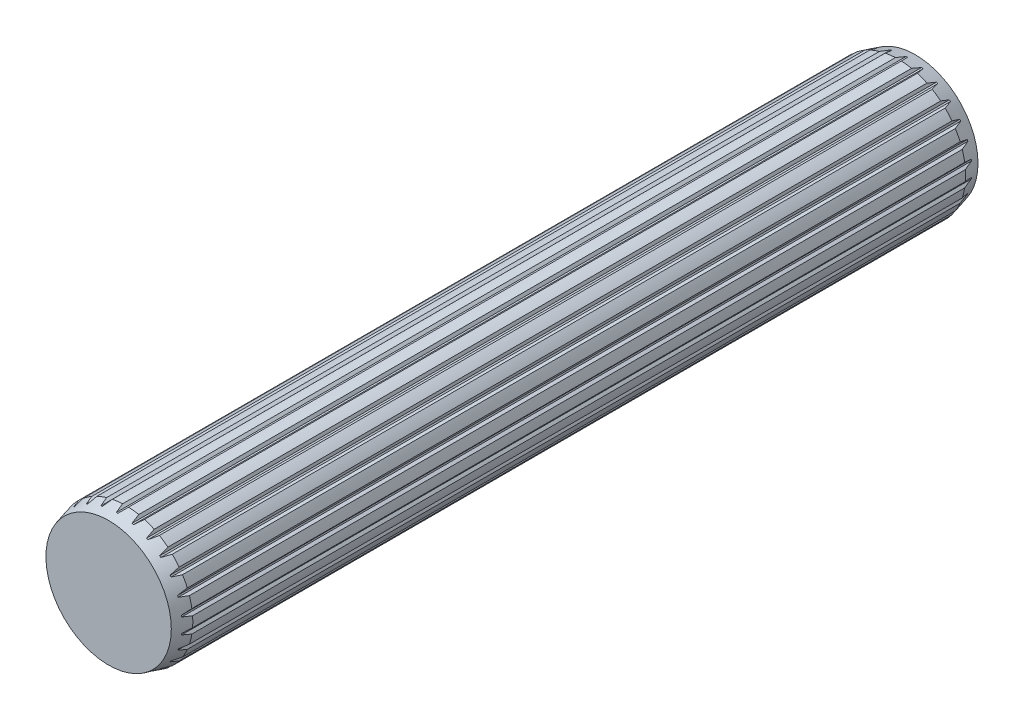
from build123d import *

# Parameters (mm, degrees)
CUT_EXTRUDE1_DEPTH = 20.05
CIRPATTERN1_COUNT  = 26


with BuildPart() as part:
    # Sketch3 → Revolve1 (revolve)
    with BuildSketch(Plane(origin=(0, 0, 0), x_dir=(0, 0, -1), z_dir=(1, 0, 0))):
        Polygon((-19.05, 2.960640646), (-19.05, 0), (19.05, 0), (19.05, 2.960640646), (18.25, 3.175), (-18.25, 3.175), align=None)
    revolve(axis=Axis((0, 0, 19.05), (0, 0, -1)))

    # Sketch5 → Cut-Extrude1 (cut, symmetric)
    with BuildSketch(Plane.XY):
        Polygon((0.142906236, 3.175), (-0.142906236, 3.175), (-0.035726559, 3.067820323), (0.035726559, 3.067820323), align=None)
    cut_extrude1 = extrude(amount=CUT_EXTRUDE1_DEPTH, both=True, mode=Mode.SUBTRACT)

    # CirPattern1: Cut-Extrude1 ×26 about axis
    cirpattern1_axis = Axis((0, 0, 0), (0, 0, 1))
    for i in range(1, CIRPATTERN1_COUNT):
        add(cut_extrude1.rotate(cirpattern1_axis, i * 360 / CIRPATTERN1_COUNT), mode=Mode.SUBTRACT)


solid = part.part
